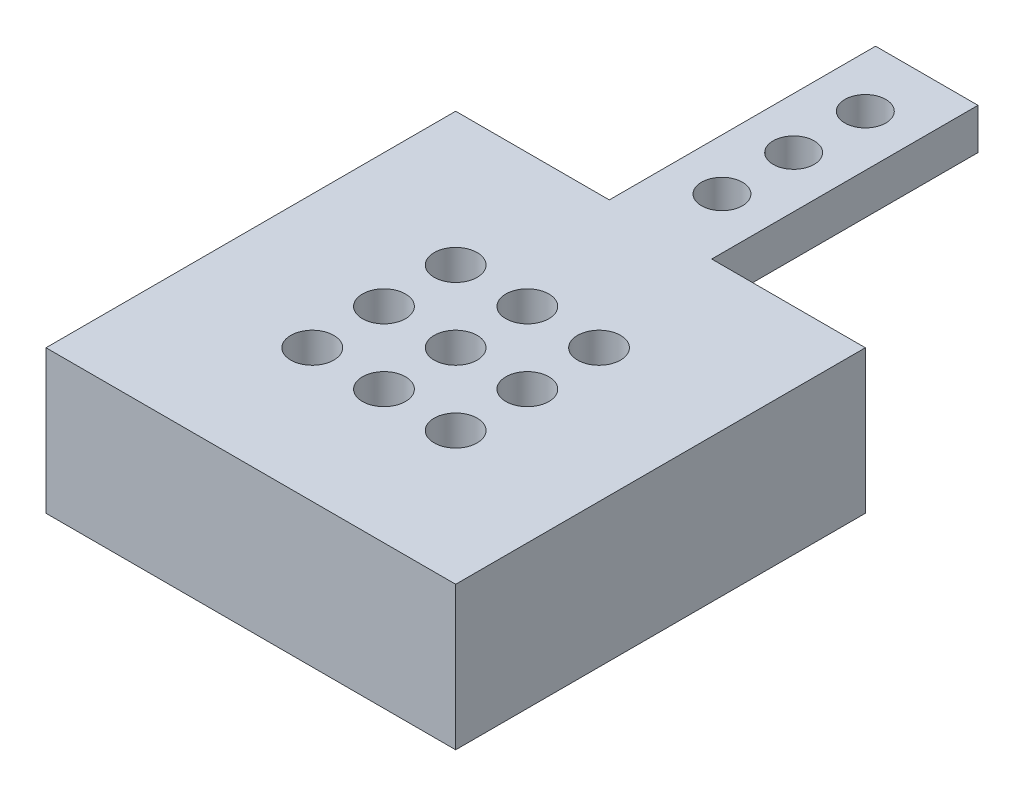
from build123d import *

# Parameters (mm, degrees)
SKETCH1_W           = 40
SKETCH1_H           = 40
BOSS_EXTRUDE1_DEPTH = 14
SKETCH4_W           = 10
SKETCH4_H           = 4
BOSS_EXTRUDE3_DEPTH = 26
SKETCH5_R           = 2
CUT_EXTRUDE2_DEPTH  = 26
SKETCH6_R           = 2.1
CUT_EXTRUDE3_DEPTH  = 15


with BuildPart() as part:
    # Sketch1 → Boss-Extrude1 (new body)
    with BuildSketch(Plane(origin=(0, 0, 0), x_dir=(1, 0, 0), z_dir=(0, 1, 0))):
        with Locations((20, 20)):
            Rectangle(SKETCH1_W, SKETCH1_H)
    extrude(amount=BOSS_EXTRUDE1_DEPTH)

    # Sketch4 → Boss-Extrude3 (add)
    with BuildSketch(Plane(origin=(0, 0, -40), x_dir=(-1, 0, 0), z_dir=(0, 0, -1))):
        with Locations((-20, 12)):
            Rectangle(SKETCH4_W, SKETCH4_H)
    extrude(amount=BOSS_EXTRUDE3_DEPTH)

    # Sketch5 → Cut-Extrude2 (cut)
    with BuildSketch(Plane(origin=(0, 14, 0), x_dir=(1, 0, 0), z_dir=(0, 1, 0))):
        with Locations((20, 60)):
            Circle(SKETCH5_R)
        with Locations((20, 53)):
            Circle(SKETCH5_R)
        with Locations((20, 46)):
            Circle(SKETCH5_R)
    extrude(amount=-CUT_EXTRUDE2_DEPTH, mode=Mode.SUBTRACT)

    # Sketch6 → Cut-Extrude3 (cut, through all)
    with BuildSketch(Plane.XZ):
        with Locations((13, -27)):
            Circle(SKETCH6_R)
        with Locations((20, -27)):
            Circle(SKETCH6_R)
        with Locations((27, -27)):
            Circle(SKETCH6_R)
        with Locations((20, -20)):
            Circle(SKETCH6_R)
        with Locations((27, -20)):
            Circle(SKETCH6_R)
        with Locations((20, -13)):
            Circle(SKETCH6_R)
        with Locations((27, -13)):
            Circle(SKETCH6_R)
        with Locations((13, -20)):
            Circle(SKETCH6_R)
        with Locations((13, -13)):
            Circle(SKETCH6_R)
    extrude(amount=-CUT_EXTRUDE3_DEPTH, mode=Mode.SUBTRACT)


solid = part.part
